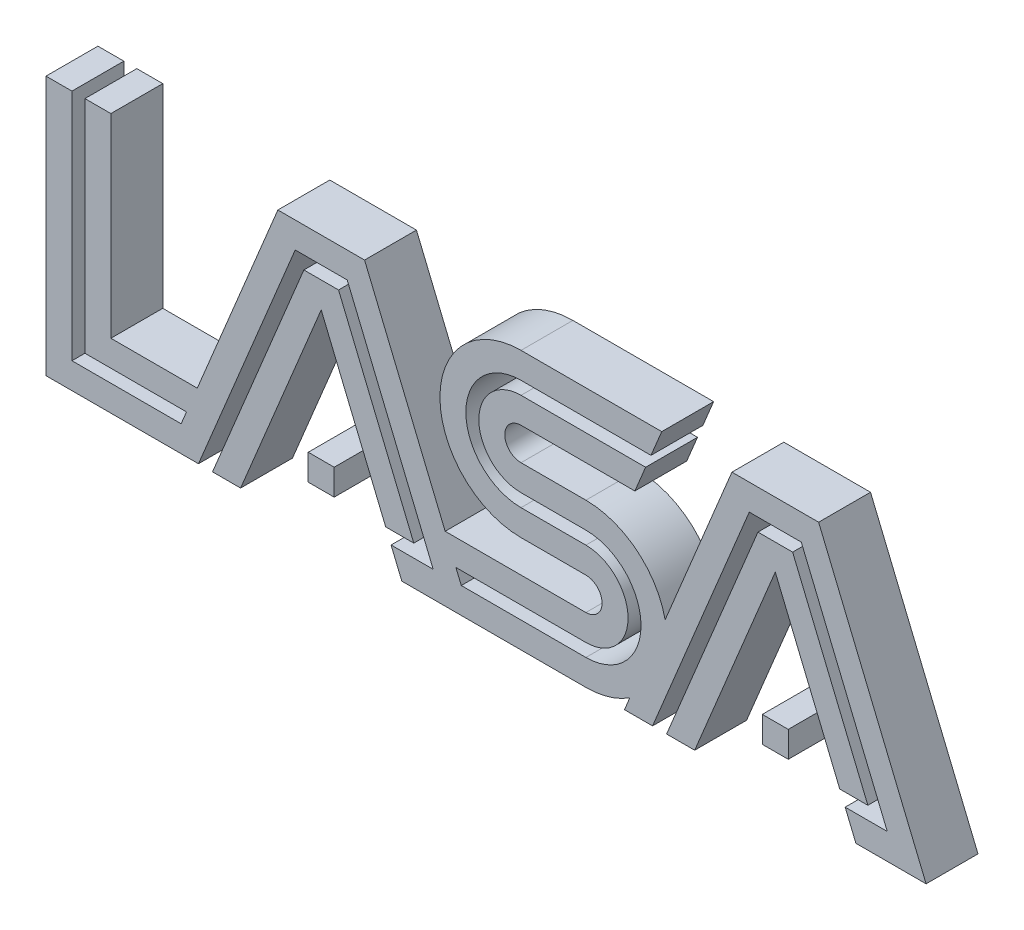
from build123d import *

# Parameters (mm, degrees)
BOSS_EXTRUDE1_DEPTH   = 20
SKETCH2_W             = 10
SKETCH2_H             = 10
BOSS_EXTRUDE1_2_DEPTH = 20
BOSS_EXTRUDE1_3_DEPTH = 20
CUT_EXTRUDE1_DEPTH    = 21


with BuildPart() as part:
    # Sketch2 → Boss-Extrude1 (new body)
    with BuildSketch(Plane.XY):
        with BuildLine():
            Line((0, 0), (0, 100))
            Line((0, 100), (25, 100))
            Line((25, 100), (25, 25))
            Line((25, 25), (58.295534052, 25))
            Line((58.295534052, 25), (89.36155123, 100))
            Line((89.36155123, 100), (122.770483126, 100))
            Line((122.770483126, 100), (153.836500304, 25))
            Line((153.836500304, 25), (208.069315713, 25))
            ThreePointArc((208.069315713, 25), (214.319315713, 31.25), (208.069315713, 37.5))
            Line((208.069315713, 37.5), (183.069315713, 37.5))
            ThreePointArc((183.069315713, 37.5), (151.819315713, 68.75), (183.069315713, 100))
            Line((183.069315713, 100), (237.301746223, 100))
            Line((237.301746223, 100), (226.946407163, 75))
            Line((226.946407163, 75), (183.069315713, 75))
            ThreePointArc((183.069315713, 75), (176.819315713, 68.75), (183.069315713, 62.5))
            Line((183.069315713, 62.5), (208.069315713, 62.5))
            ThreePointArc((208.069315713, 62.5), (227.697097013, 55.566922117), (238.615698382, 37.844012879))
            Line((238.615698382, 37.844012879), (264.36155123, 100))
            Line((264.36155123, 100), (297.770483126, 100))
            Line((297.770483126, 100), (339.191839363, 0))
            Line((339.191839363, 0), (312.132034356, 0))
            Line((312.132034356, 0), (281.066017178, 75))
            Line((281.066017178, 75), (250, 0))
            Line((250, 0), (222.940194993, 0))
            Line((222.940194993, 0), (225.006198817, 4.987774452))
            ThreePointArc((225.006198817, 4.987774452), (216.897337905, 1.272866645), (208.069315713, 0))
            Line((208.069315713, 0), (137.132034356, 0))
            Line((137.132034356, 0), (106.066017178, 75))
            Line((106.066017178, 75), (75, 0))
            Line((75, 0), (0, 0))
        make_face()
    extrude(amount=BOSS_EXTRUDE1_DEPTH)

    # Sketch5 → Cut-Extrude1 (cut, through all)
    with BuildSketch(Plane.XY.offset(20)):
        Polygon((10, 100), (10, 10), (52.082330616, 10), (54.153398428, 15), (15, 15), (15, 100), align=None)
        Polygon((64.176077997, 0), (99.384230799, 85), (112.747803557, 85), (141.742752923, 15), (130.91883092, 15), (132.989898732, 10), (149.225781737, 10), (116.088696747, 90), (96.043337609, 90), (58.764116996, 0), align=None)
        with BuildLine():
            Line((231.088542787, 85), (233.159610599, 90))
            Line((233.159610599, 90), (183.069315713, 90))
            ThreePointArc((183.069315713, 90), (161.819315713, 68.75), (183.069315713, 47.5))
            Line((183.069315713, 47.5), (208.069315713, 47.5))
            ThreePointArc((208.069315713, 47.5), (224.319315713, 31.25), (208.069315713, 15))
            Line((208.069315713, 15), (157.978635928, 15))
            Line((157.978635928, 15), (160.04970374, 10))
            Line((160.04970374, 10), (208.069315713, 10))
            ThreePointArc((208.069315713, 10), (229.319315713, 31.25), (208.069315713, 52.5))
            Line((208.069315713, 52.5), (183.069315713, 52.5))
            ThreePointArc((183.069315713, 52.5), (166.819315713, 68.75), (183.069315713, 85))
            Line((183.069315713, 85), (231.088542787, 85))
        make_face()
        Polygon((239.176077997, 0), (233.764116996, 0), (271.043337609, 90), (291.088696747, 90), (324.225781737, 10), (307.989898732, 10), (305.91883092, 15), (316.742752923, 15), (287.747803557, 85), (274.384230799, 85), align=None)
    extrude(amount=-CUT_EXTRUDE1_DEPTH, mode=Mode.SUBTRACT)


with BuildPart() as body_2:
    # Sketch2 → Boss-Extrude1 2 (new body)
    with BuildSketch(Plane.XY):
        with Locations((106.066017178, 20)):
            Rectangle(SKETCH2_W, SKETCH2_H)
    extrude(amount=BOSS_EXTRUDE1_2_DEPTH)


with BuildPart() as body_3:
    # Sketch2 → Boss-Extrude1 3 (new body)
    with BuildSketch(Plane.XY):
        with Locations((281.066017178, 20)):
            Rectangle(SKETCH2_W, SKETCH2_H)
    extrude(amount=BOSS_EXTRUDE1_3_DEPTH)


solid = Compound([part.part, body_2.part, body_3.part])
